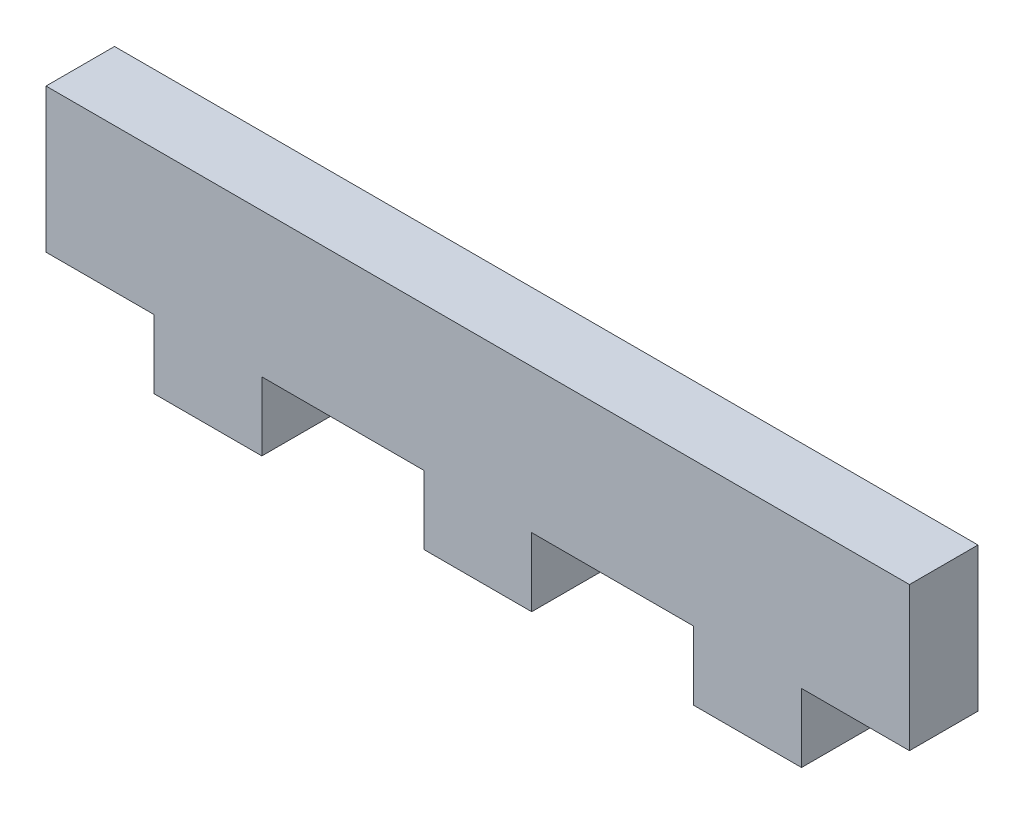
from build123d import *

# Parameters (mm, degrees)
BOSS_EXTRUDE1_DEPTH = 3.175


with BuildPart() as part:
    # Sketch1 → Boss-Extrude1 (new body)
    with BuildSketch(Plane.XY):
        Polygon((-20, -3.333333333), (-15, -3.333333333), (-15, -6.508333333), (-10, -6.508333333), (-10, -3.333333333), (-2.5, -3.333333333), (-2.5, -6.508333333), (2.5, -6.508333333), (2.5, -3.333333333), (10, -3.333333333), (10, -6.508333333), (15, -6.508333333), (15, -3.333333333), (20, -3.333333333), (20, 3.333333333), (-20, 3.333333333), align=None)
    extrude(amount=BOSS_EXTRUDE1_DEPTH)


solid = part.part
